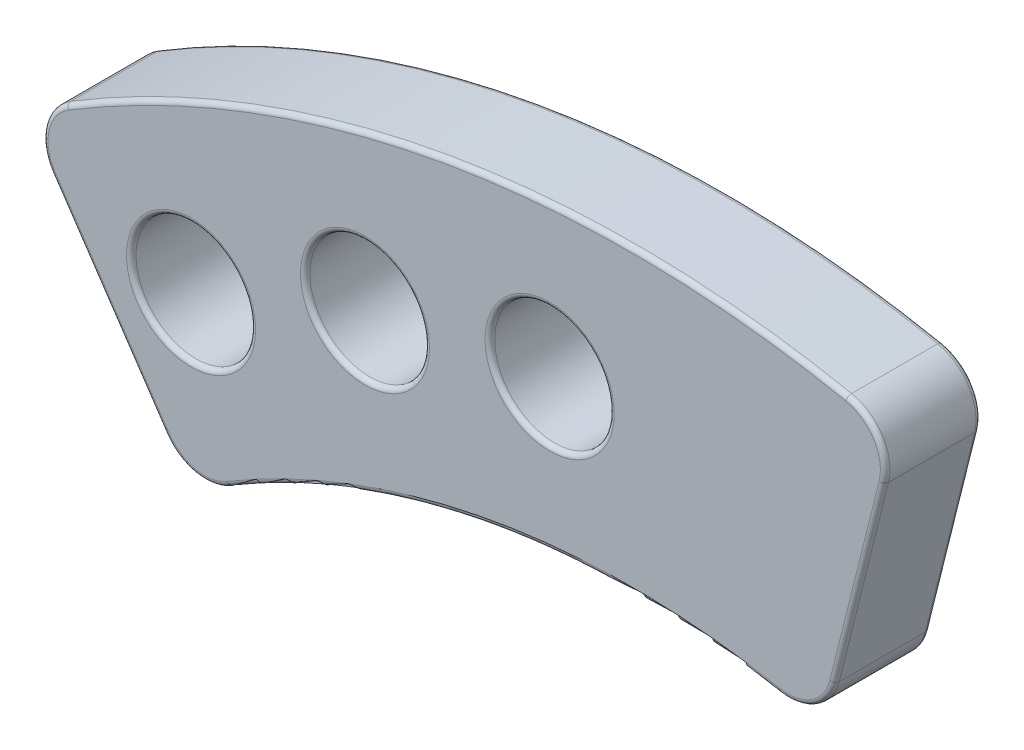
from build123d import *

# Parameters (mm, degrees)
SCHIZZO1_R                   = 2.5
ESTRUSIONE_ESTRUSIONE1_DEPTH = 4
RACCORDO1_R                  = 2
RACCORDO2_R                  = 0.2


with BuildPart() as part:
    # Schizzo1 → Estrusione-Estrusione1 (new body)
    with BuildSketch(Plane.XY):
        with BuildLine():
            Line((11.033009039, 44.137450458), (8.000831447, 32.009875619))
            ThreePointArc((8.000831447, 32.009875619), (-5.714758863, 32.495953165), (-18.441601255, 27.359692691))
            Line((-18.441601255, 27.359692691), (-25.428689404, 37.725635535))
            ThreePointArc((-25.428689404, 37.725635535), (-7.879514321, 44.807980042), (11.033009039, 44.137450458))
        make_face()
        with Locations((-3.439792426, 39.094033001)):
            Circle(SCHIZZO1_R, mode=Mode.SUBTRACT)
        with Locations((-11.164834184, 37.62342443)):
            Circle(SCHIZZO1_R, mode=Mode.SUBTRACT)
        with Locations((-18.441601255, 34.642213142)):
            Circle(SCHIZZO1_R, mode=Mode.SUBTRACT)
    extrude(amount=ESTRUSIONE_ESTRUSIONE1_DEPTH)

    # Raccordo1
    raccordo1_edges = [part.edges().sort_by_distance(p)[0] for p in [
        (8.000831447, 32.009875619, 2),
        (-18.441601255, 27.359692691, 2),
        (-25.428689404, 37.725635535, 2),
        (11.033009039, 44.137450458, 2),
    ]]
    fillet(raccordo1_edges, radius=RACCORDO1_R)

    # Raccordo2
    raccordo2_edges = [part.edges().sort_by_distance(p)[0] for p in [
        (-20.941601255, 34.642213142, 0),
        (-13.664834184, 37.62342443, 0),
        (-5.939792426, 39.094033001, 0),
        (-13.664834184, 37.62342443, 4),
        (-20.941601255, 34.642213142, 4),
        (-5.714695459, 32.495964315, 0),
        (-5.714695459, 32.495964315, 4),
        (9.504374759, 38.023485803, 0),
        (-21.906303429, 32.499874688, 0),
        (-7.879568016, 44.807970599, 0),
        (-24.580509728, 37.574199755, 0),
        (10.287299472, 43.705721167, 0),
        (7.609381939, 32.694788408, 0),
        (-18.307264578, 28.137148594, 0),
        (-21.906303429, 32.499874688, 4),
        (9.504374759, 38.023485803, 4),
        (-7.879568016, 44.807970599, 4),
        (-24.580509728, 37.574199755, 4),
        (10.287299472, 43.705721167, 4),
        (7.609381939, 32.694788408, 4),
        (-18.307264578, 28.137148594, 4),
        (-5.939792426, 39.094033001, 4),
    ]]
    fillet(raccordo2_edges, radius=RACCORDO2_R)


solid = part.part
